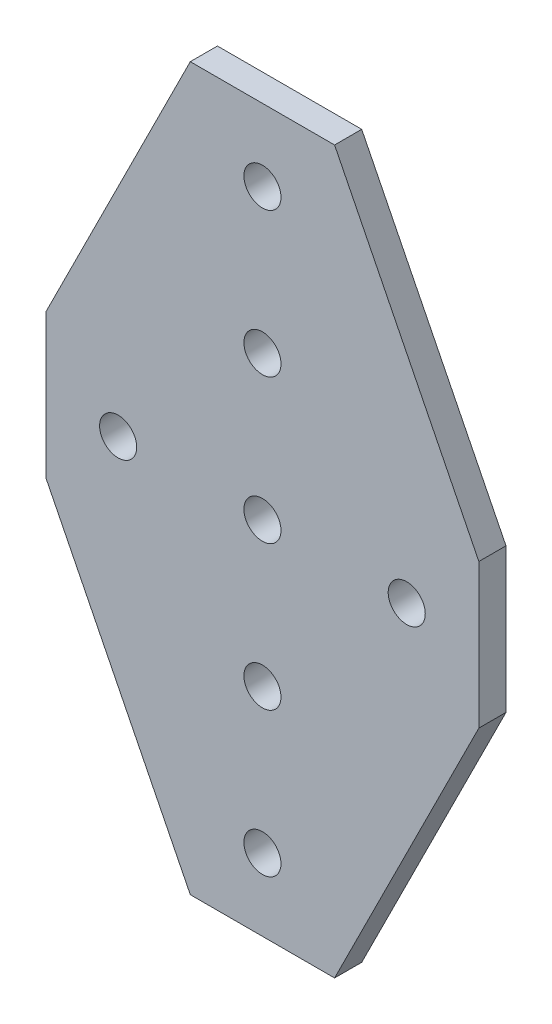
from build123d import *

# Parameters (mm, degrees)
BOSS_EXTRUDE1_DEPTH      = 2.3876
BOSS_EXTRUDE1_DEPTH_BACK = 2.3876
SKETCH4_R                = 3.2639
CUT_EXTRUDE1_DEPTH       = 1
CUT_EXTRUDE1_DEPTH_BACK  = 5.7752
SKETCH5_R                = 3.2639
CUT_EXTRUDE2_DEPTH       = 5.7752


with BuildPart() as part:
    # Sketch3 → Boss-Extrude1 (new body, two sides)
    with BuildSketch(Plane.XY) as boss_extrude1_sk:
        Polygon((-12.7, 63.5), (12.7, 63.5), (38.1, 12.7), (38.1, -12.7), (12.7, -63.5), (-12.7, -63.5), (-38.1, -12.7), (-38.1, 12.7), align=None)
    extrude(amount=BOSS_EXTRUDE1_DEPTH)
    extrude(boss_extrude1_sk.sketch, amount=-BOSS_EXTRUDE1_DEPTH_BACK)

    # Sketch4 → Cut-Extrude1 (cut, two sides)
    with BuildSketch(Plane.XY.offset(2.3876)) as cut_extrude1_sk:
        with Locations((0, 50.8)):
            Circle(SKETCH4_R)
        with Locations((0, 25.4)):
            Circle(SKETCH4_R)
        Circle(SKETCH4_R)
        with Locations((0, -25.4)):
            Circle(SKETCH4_R)
        with Locations((0, -50.8)):
            Circle(SKETCH4_R)
    extrude(amount=CUT_EXTRUDE1_DEPTH, mode=Mode.SUBTRACT)
    extrude(cut_extrude1_sk.sketch, amount=-CUT_EXTRUDE1_DEPTH_BACK, mode=Mode.SUBTRACT)

    # Sketch5 → Cut-Extrude2 (cut, through all)
    with BuildSketch(Plane.XY.offset(2.3876)):
        with Locations((25.4, 0)):
            Circle(SKETCH5_R)
        with Locations((-25.4, 0)):
            Circle(SKETCH5_R)
    extrude(amount=-CUT_EXTRUDE2_DEPTH, mode=Mode.SUBTRACT)


solid = part.part
